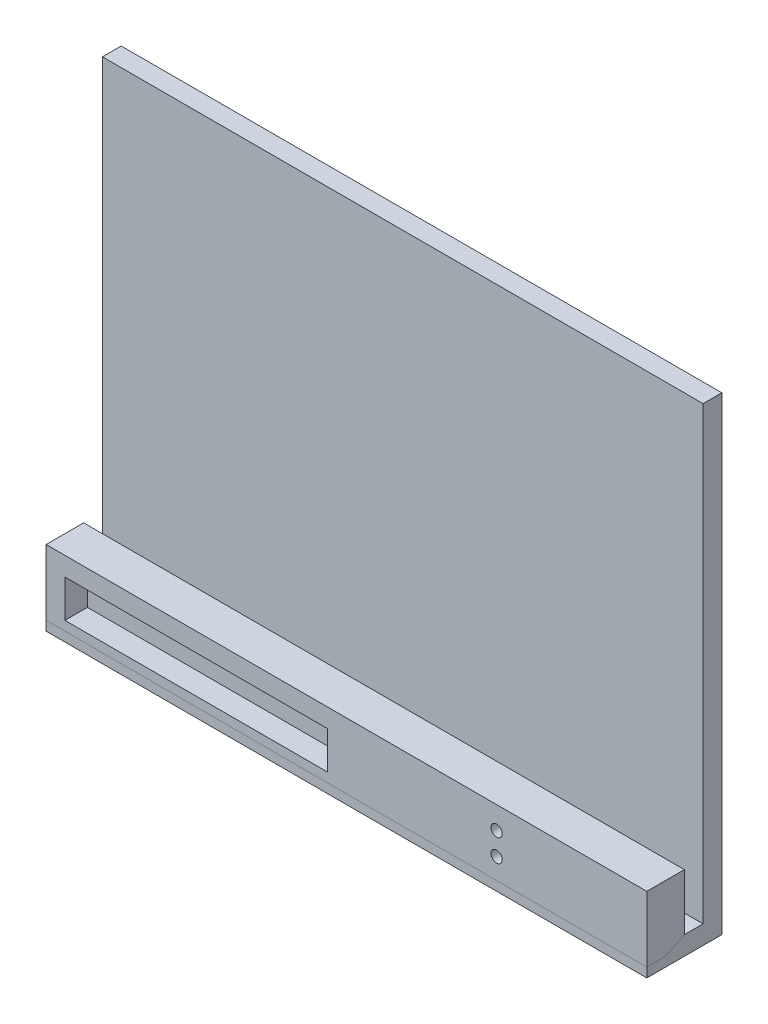
from build123d import *

# Parameters (mm, degrees)
SKETCH1_W              = 203.2
SKETCH1_H              = 158.75
BOSS_EXTRUDE1_DEPTH    = 6.35
SKETCH2_W              = 203.2
SKETCH2_H              = 6.35
BOSS_EXTRUDE2_DEPTH    = 19.05
SKETCH3_W              = 203.2
SKETCH3_H              = 12.7
BOSS_EXTRUDE3_DEPTH    = 19.05
SKETCH4_W              = 88.9
SKETCH4_H              = 12.7
CUT_EXTRUDE1_DEPTH     = 7.62
CUT_EXTRUDE2_REACH     = 261.108
SKETCH5_R              = 1.905
SPLIT1_SURFACE_1_BACK  = 260.108
SPLIT1_SURFACE_1_DEPTH = 520.216
SPLIT1_SURFACE_2_BACK  = 260.108
SPLIT1_SURFACE_2_DEPTH = 520.216


with BuildPart() as part:
    # Sketch1 → Boss-Extrude1 (new body)
    with BuildSketch(Plane.XY):
        with Locations((101.6, 79.375)):
            Rectangle(SKETCH1_W, SKETCH1_H)
    extrude(amount=BOSS_EXTRUDE1_DEPTH)

    # Sketch2 → Boss-Extrude2 (add)
    with BuildSketch(Plane.XY.offset(6.35)):
        with Locations((101.6, 3.175)):
            Rectangle(SKETCH2_W, SKETCH2_H)
    extrude(amount=BOSS_EXTRUDE2_DEPTH)

    # Sketch3 → Boss-Extrude3 (add)
    with BuildSketch(Plane(origin=(0, 6.35, 0), x_dir=(1, 0, 0), z_dir=(0, 1, 0))):
        with Locations((101.6, -19.05)):
            Rectangle(SKETCH3_W, SKETCH3_H)
    extrude(amount=BOSS_EXTRUDE3_DEPTH)

    # Sketch4 → Cut-Extrude1 (cut)
    with BuildSketch(Plane.XY.offset(25.4)):
        with Locations((50.8, 12.7)):
            Rectangle(SKETCH4_W, SKETCH4_H)
    extrude(amount=-CUT_EXTRUDE1_DEPTH, mode=Mode.SUBTRACT)

    # Sketch5 → Cut-Extrude2 (cut, up to next)
    with BuildSketch(Plane.XY.offset(25.4), mode=Mode.PRIVATE) as cut_extrude2_sk1:
        with Locations((152.4, 17.78)):
            Circle(SKETCH5_R)
    cut_extrude2_tool1 = extrude(cut_extrude2_sk1.sketch, amount=-CUT_EXTRUDE2_REACH, mode=Mode.PRIVATE) & part.part
    # Sketch5 → Cut-Extrude2 (cut, up to next)
    with BuildSketch(Plane.XY.offset(25.4), mode=Mode.PRIVATE) as cut_extrude2_sk2:
        with Locations((152.4, 10.16)):
            Circle(SKETCH5_R)
    cut_extrude2_tool2 = extrude(cut_extrude2_sk2.sketch, amount=-CUT_EXTRUDE2_REACH, mode=Mode.PRIVATE) & part.part
    add(cut_extrude2_tool1.solids().sort_by_distance((152.4, 17.78, 25.4))[0], mode=Mode.SUBTRACT)
    add(cut_extrude2_tool2.solids().sort_by_distance((152.4, 10.16, 25.4))[0], mode=Mode.SUBTRACT)


with BuildPart() as body_2:
    # Split1: the piece behind the surface
    add(part.part)
    # Split1 surface: a surface, the sketch's curves swept straight by 520.216 mm
    with BuildLine(Plane(origin=(203.2, 0, 0), x_dir=(0, 0, -1), z_dir=(1, 0, 0)).offset(-SPLIT1_SURFACE_1_BACK), mode=Mode.PRIVATE) as split1_surface_1_path:
        Line((-25.4, 3.175), (-19.05, 3.175))
        Line((-19.05, 3.175), (-12.7, 6.35))
    split1_surface_1 = Shell.extrude(split1_surface_1_path.wire(), (1 * SPLIT1_SURFACE_1_DEPTH, 0 * SPLIT1_SURFACE_1_DEPTH, 0 * SPLIT1_SURFACE_1_DEPTH))
    split(bisect_by=split1_surface_1, keep=Keep.BOTTOM)


with BuildPart() as part_1:
    add(part.part)

    # Split1: split by a surface, the side it looks to stays
    # Split1 surface: a surface, the sketch's curves swept straight by 520.216 mm
    with BuildLine(Plane(origin=(203.2, 0, 0), x_dir=(0, 0, -1), z_dir=(1, 0, 0)).offset(-SPLIT1_SURFACE_2_BACK), mode=Mode.PRIVATE) as split1_surface_2_path:
        Line((-25.4, 3.175), (-19.05, 3.175))
        Line((-19.05, 3.175), (-12.7, 6.35))
    split1_surface_2 = Shell.extrude(split1_surface_2_path.wire(), (1 * SPLIT1_SURFACE_2_DEPTH, 0 * SPLIT1_SURFACE_2_DEPTH, 0 * SPLIT1_SURFACE_2_DEPTH))
    split(bisect_by=split1_surface_2, keep=Keep.TOP)


solid = Compound([body_2.part, part_1.part])
